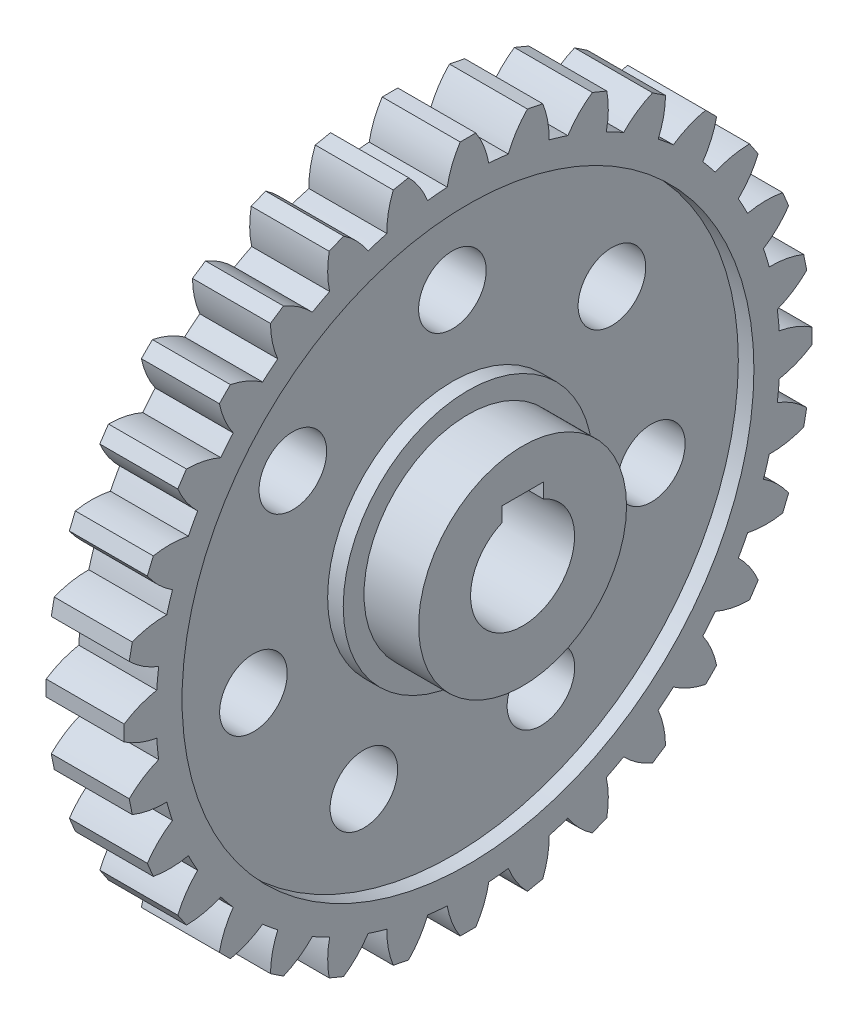
from build123d import *

# Parameters (mm, degrees)
SKETCH1_R           = 60
BOSS_EXTRUDE1_DEPTH = 7.5
BOSS_EXTRUDE2_DEPTH = 15
SKETCH5_R           = 20
BOSS_EXTRUDE5_DEPTH = 18
CUT_EXTRUDE1_DEPTH  = 37
SKETCH7_R           = 55
SKETCH7_R_2         = 24
CUT_EXTRUDE2_DEPTH  = 3
SKETCH8_R           = 6.5
CUT_EXTRUDE3_DEPTH  = 23.5
CIRPATTERN2_COUNT   = 32


with BuildPart() as part:
    # Sketch1 → Boss-Extrude1 (new body, symmetric)
    with BuildSketch(Plane(origin=(0, 0, 0), x_dir=(0, 0, -1), z_dir=(1, 0, 0))):
        Circle(SKETCH1_R)
    extrude(amount=BOSS_EXTRUDE1_DEPTH, both=True)

    # Sketch2 → Boss-Extrude2 (add)
    with BuildSketch(Plane(origin=(7.5, 0, 0), x_dir=(0, 0, -1), z_dir=(1, 0, 0))):
        with BuildLine():
            Line((-1.5, 66.136518188), (1.5, 66.136518188))
            ThreePointArc((1.5, 66.136518188), (3.064324573, 63.126846965), (4, 59.866518188))
            ThreePointArc((4, 59.866518188), (0, 60), (-4, 59.866518188))
            ThreePointArc((-4, 59.866518188), (-3.064324573, 63.126846965), (-1.5, 66.136518188))
        make_face()
    boss_extrude2 = extrude(amount=-BOSS_EXTRUDE2_DEPTH)

    # Sketch5 → Boss-Extrude5 (add, symmetric)
    with BuildSketch(Plane(origin=(0, 0, 0), x_dir=(0, 0, -1), z_dir=(1, 0, 0))):
        Circle(SKETCH5_R)
    extrude(amount=BOSS_EXTRUDE5_DEPTH, both=True)

    # Sketch6 → Cut-Extrude1 (cut, through all)
    with BuildSketch(Plane(origin=(18, 0, 0), x_dir=(0, 0, -1), z_dir=(1, 0, 0))):
        with BuildLine():
            Line((-4, 12), (4, 12))
            Line((4, 12), (4, 9.16515139))
            ThreePointArc((4, 9.16515139), (0, -10), (-4, 9.16515139))
            Line((-4, 9.16515139), (-4, 12))
        make_face()
    extrude(amount=-CUT_EXTRUDE1_DEPTH, mode=Mode.SUBTRACT)

    # Sketch7 → Cut-Extrude2 (cut)
    with BuildSketch(Plane(origin=(7.5, 0, 0), x_dir=(0, 0, -1), z_dir=(1, 0, 0))):
        Circle(SKETCH7_R)
        Circle(SKETCH7_R_2, mode=Mode.SUBTRACT)
    extrude(amount=-CUT_EXTRUDE2_DEPTH, mode=Mode.SUBTRACT)

    # Sketch8 → Cut-Extrude3 (cut, through all)
    with BuildSketch(Plane(origin=(4.5, 0, 0), x_dir=(0, 0, -1), z_dir=(1, 0, 0))):
        with Locations((0, 39.25)):
            Circle(SKETCH8_R)
        with Locations((30.686885687, 24.471974723)):
            Circle(SKETCH8_R)
        with Locations((38.265920553, -8.733946658)):
            Circle(SKETCH8_R)
        with Locations((17.02993676, -35.363028065)):
            Circle(SKETCH8_R)
        with Locations((-17.02993676, -35.363028065)):
            Circle(SKETCH8_R)
        with Locations((-38.265920553, -8.733946658)):
            Circle(SKETCH8_R)
        with Locations((-30.686885687, 24.471974723)):
            Circle(SKETCH8_R)
    extrude(amount=-CUT_EXTRUDE3_DEPTH, mode=Mode.SUBTRACT)

    # CirPattern2: Boss-Extrude2 ×32 about axis
    cirpattern2_axis = Axis((0, 0, 0), (1, 0, 0))
    for i in range(1, CIRPATTERN2_COUNT):
        add(boss_extrude2.rotate(cirpattern2_axis, i * 360 / CIRPATTERN2_COUNT))


solid = part.part
